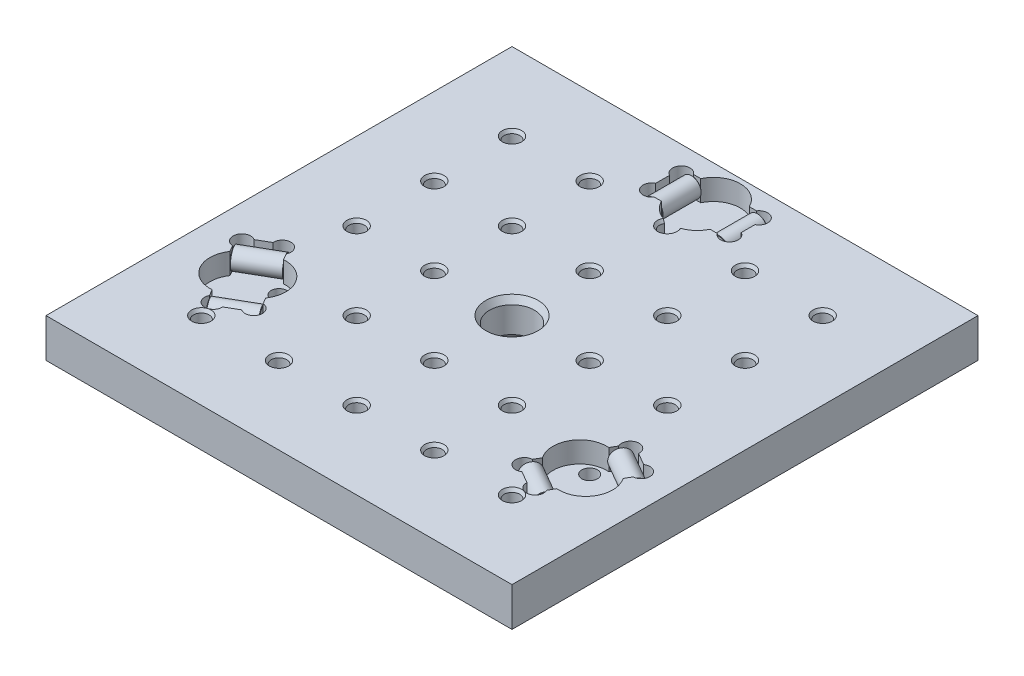
from build123d import *

# Parameters (mm, degrees)
SKETCH1_W            = 152.4
SKETCH1_H            = 152.4
EXTRUDE1_DEPTH       = 12.7
LPATTERN1_COUNT      = 5
LPATTERN1_PITCH      = 25.4
LPATTERN1_COUNT_DIR2 = 5
LPATTERN1_PITCH_DIR2 = 25.4
CUT_EXTRUDE1_DEPTH   = 6.858
CUT_EXTRUDE2_DEPTH   = 6.858
SKETCH10_R           = 3.175
EXTRUDE2_DEPTH       = 6.35
EXTRUDE2_2_DEPTH     = 6.35
CHAMFER1_SIZE        = 0.127
CHAMFER2_SIZE        = 0.127
CIRPATTERN4_COUNT    = 3
CIRPATTERN5_COUNT    = 3
SKETCH97_W           = 1.527820346
SKETCH97_H           = 0.474151141
CUT_EXTRUDE25_DEPTH  = 0.0762


with BuildPart() as part:
    # Sketch1 → Extrude1 (new body)
    with BuildSketch(Plane(origin=(0, 0, 0), x_dir=(1, 0, 0), z_dir=(0, 1, 0))):
        Rectangle(SKETCH1_W, SKETCH1_H)
    extrude(amount=EXTRUDE1_DEPTH)

    # Sketch4 → 5_8-18 Tapped Hole1 (revolve, cut)
    with BuildSketch(Plane(origin=(0, 12.7, 0), x_dir=(0, 0, 1), z_dir=(1, 0, 0))):
        Polygon((0, 0), (0, 12.7), (8.5725, 12.7), (7.34187, 10.568486315), (7.34187, 2.131513685), (8.5725, 0), align=None)
    revolve(axis=Axis((0, 19.05, 0), (0, -1, 0)), mode=Mode.SUBTRACT)

    # Sketch5 → 1_4-20 Tapped Hole1 (revolve, cut)
    with BuildSketch(Plane(origin=(-50.8, 12.7, -50.8), x_dir=(0, 0, 1), z_dir=(1, 0, 0))):
        Polygon((0, 0), (0, 12.7), (3.175, 12.7), (2.5527, 11.622144782), (2.5527, 1.077855218), (3.175, 0), align=None)
    f_1_4_20_tapped_hole1 = revolve(axis=Axis((-50.8, 19.05, -50.8), (0, -1, 0)), mode=Mode.SUBTRACT)

    # LPattern1: 1_4-20 Tapped Hole1 5 × 5, 1 skipped
    with Locations(*[(i * LPATTERN1_PITCH, 0, j * LPATTERN1_PITCH_DIR2) for i in range(LPATTERN1_COUNT) for j in range(LPATTERN1_COUNT_DIR2) if (i, j) not in ((0, 0), (2, 2))]):
        add(f_1_4_20_tapped_hole1, mode=Mode.SUBTRACT)

    # Sketch8 → Cut-Extrude1 (cut)
    with BuildSketch(Plane(origin=(0, 12.7, 0), x_dir=(-1, 0, 0), z_dir=(0, 1, 0))):
        with BuildLine():
            Line((7.9375, -69.6595), (7.9375, -56.8325))
            ThreePointArc((7.9375, -56.8325), (0, -51.816), (-7.9375, -56.8325))
            Line((-7.9375, -56.8325), (-7.9375, -69.6595))
            ThreePointArc((-7.9375, -69.6595), (0, -74.676), (7.9375, -69.6595))
        make_face()
    cut_extrude1 = extrude(amount=-CUT_EXTRUDE1_DEPTH, mode=Mode.SUBTRACT)

    # Sketch9 → Cut-Extrude2 (cut)
    with BuildSketch(Plane(origin=(0, 12.7, 0), x_dir=(-1, 0, 0), z_dir=(0, 1, 0))):
        with BuildLine():
            Line((-13.97, -65.512233165), (-13.97, -60.979766835))
            ThreePointArc((-13.97, -60.979766835), (-14.846098379, -56.533318257), (-10.324047559, -56.8325))
            Line((-10.324047559, -56.8325), (-7.9375, -56.8325))
            Line((-7.9375, -56.8325), (-7.9375, -69.6595))
            Line((-7.9375, -69.6595), (-10.324047559, -69.6595))
            ThreePointArc((-10.324047559, -69.6595), (-14.846098379, -69.958681743), (-13.97, -65.512233165))
        make_face()
        with BuildLine():
            Line((7.9375, -69.6595), (7.9375, -56.8325))
            Line((7.9375, -56.8325), (10.324047559, -56.8325))
            ThreePointArc((10.324047559, -56.8325), (14.846098379, -56.533318257), (13.97, -60.979766835))
            Line((13.97, -60.979766835), (13.97, -65.512233165))
            ThreePointArc((13.97, -65.512233165), (14.846098379, -69.958681743), (10.324047559, -69.6595))
            Line((10.324047559, -69.6595), (7.9375, -69.6595))
        make_face()
    cut_extrude2 = extrude(amount=-CUT_EXTRUDE2_DEPTH, mode=Mode.SUBTRACT)

    # CirPattern4: Cut-Extrude1, Cut-Extrude2 ×3 about axis
    cirpattern4_axis = Axis((0, 0, 0), (0, 1, 0))
    add([cut_extrude1.rotate(cirpattern4_axis, i * 360 / CIRPATTERN4_COUNT) for i in range(1, CIRPATTERN4_COUNT)], mode=Mode.SUBTRACT)
    add([cut_extrude2.rotate(cirpattern4_axis, i * 360 / CIRPATTERN4_COUNT) for i in range(1, CIRPATTERN4_COUNT)], mode=Mode.SUBTRACT)

    # Sketch97 → Cut-Extrude25 (cut)
    with BuildSketch(Plane(origin=(0, 0, -76.2), x_dir=(-1, 0, 0), z_dir=(0, 0, -1))):
        with BuildLine():
            Line((28.343701589, 8.89), (28.343701589, 4.780690104))
            Line((28.343701589, 4.780690104), (26.805179915, 4.780690104))
            add(Edge.make_bspline(
                [(26.805179915, 4.780690104), (26.767027271, 4.780837069), (26.692580616, 4.781123838), (26.583870621, 4.78825798), (26.480923337, 4.798056689), (26.383475532, 4.810548566), (26.292159048, 4.82915713), (26.206241303, 4.850130709), (26.126166613, 4.875632264), (26.028364377, 4.914665889), (25.915972121, 4.974246047), (25.795845315, 5.064344499), (25.691219749, 5.171552892), (25.60371681, 5.294067497), (25.534594896, 5.426352035), (25.483695852, 5.563436916), (25.451614062, 5.703641399), (25.447943468, 5.798523221), (25.446111278, 5.845883815)],
                knots=[0, 0, 0, 0, 0.939347082, 1.832933197, 2.68146557, 3.486110826, 4.250749273, 4.975125432, 5.663232023, 6.31822681, 7.566717696, 8.783012481, 10.001501375, 11.241036602, 12.477233666, 13.665923641, 14.834937602, 16, 16, 16, 16], degree=3))
            add(Edge.make_bspline(
                [(25.446111278, 5.845883815), (25.448029443, 5.889950382), (25.451847281, 5.977658674), (25.482209262, 6.106861747), (25.530059037, 6.231953365), (25.597517328, 6.352075791), (25.683483577, 6.465437327), (25.792018553, 6.566315567), (25.918574081, 6.657033193), (26.01364719, 6.705160765), (26.062672398, 6.729978132)],
                knots=[0, 0, 0, 0, 0.9266367, 1.844339749, 2.778522519, 3.737737271, 4.73460122, 5.760014721, 6.844933715, 8, 8, 8, 8], degree=3))
            add(Edge.make_bspline(
                [(26.062672398, 6.729978132), (26.032355949, 6.739468376), (25.9730015, 6.758048659), (25.887674658, 6.792049377), (25.807573685, 6.830758713), (25.73254819, 6.874264218), (25.663018861, 6.922882375), (25.599642241, 6.976876442), (25.54065759, 7.034364659), (25.488044634, 7.097172521), (25.441158142, 7.163934323), (25.399946612, 7.233763871), (25.365176883, 7.306463207), (25.337173228, 7.382040444), (25.314688945, 7.460390746), (25.299242268, 7.541954145), (25.290081105, 7.626484486), (25.288741754, 7.683745432), (25.288060897, 7.712853936)],
                knots=[0, 0, 0, 0, 1.127307071, 2.207075445, 3.256908754, 4.282608941, 5.282408985, 6.263870425, 7.234983269, 8.202720022, 9.167413107, 10.127917746, 11.077645759, 12.02382113, 12.985756818, 13.967604811, 14.966835385, 16, 16, 16, 16], degree=3))
            add(Edge.make_bspline(
                [(25.288060897, 7.712853936), (25.289371695, 7.759604508), (25.29197112, 7.852314976), (25.316112373, 7.988060339), (25.352938012, 8.119232659), (25.405671395, 8.242690266), (25.468517888, 8.357267108), (25.538968496, 8.459754921), (25.616848014, 8.548372818), (25.703374026, 8.62285082), (25.798997976, 8.686242285), (25.904927798, 8.740367396), (26.021826423, 8.786539687), (26.150489328, 8.8243588), (26.292528418, 8.853926746), (26.448798142, 8.874604377), (26.62000089, 8.888161147), (26.739022879, 8.889369918), (26.80106402, 8.89)],
                knots=[0, 0, 0, 0, 1.028264767, 2.039138877, 3.0256281, 4.021796415, 4.986880544, 5.898364145, 6.754107619, 7.576323729, 8.403891453, 9.273758037, 10.190131768, 11.166715241, 12.222223064, 13.380548297, 14.634590339, 16, 16, 16, 16], degree=3))
            Line((26.80106402, 8.89), (28.343701589, 8.89))
        make_face()
        with BuildLine():
            Line((27.764183527, 6.519244291), (26.917132268, 6.519244291))
            add(Edge.make_bspline(
                [(26.917132268, 6.519244291), (26.889414642, 6.519134629), (26.836162821, 6.518923945), (26.759348338, 6.515986377), (26.688452252, 6.513480211), (26.623748799, 6.507189927), (26.564917433, 6.501028874), (26.512193589, 6.492735135), (26.465319023, 6.483389974), (26.436617718, 6.474721633), (26.423224829, 6.470676726)],
                knots=[0, 0, 0, 0, 1.335841395, 2.566453063, 3.705076039, 4.753984432, 5.69893722, 6.555639608, 7.326018133, 8, 8, 8, 8], degree=3))
            add(Edge.make_bspline(
                [(26.423224829, 6.470676726), (26.391743301, 6.459668671), (26.331053502, 6.438447445), (26.249751718, 6.389868761), (26.17974209, 6.332527084), (26.122805167, 6.263581733), (26.078926377, 6.185119142), (26.047245007, 6.097331853), (26.02952658, 5.999976239), (26.026960242, 5.932114161), (26.02562934, 5.896920917)],
                knots=[0, 0, 0, 0, 1.058475706, 2.04051966, 2.99494362, 3.924783233, 4.866712143, 5.841396942, 6.880549411, 8, 8, 8, 8], degree=3))
            add(Edge.make_bspline(
                [(26.02562934, 5.896920917), (26.026690543, 5.863100034), (26.028758706, 5.797187032), (26.046245347, 5.701206754), (26.076327559, 5.612060138), (26.115884571, 5.529158253), (26.168200469, 5.456442373), (26.23029981, 5.394031401), (26.304164625, 5.346138892), (26.373217924, 5.316473689), (26.435289253, 5.297883421), (26.4907538, 5.286889521), (26.553665226, 5.277200941), (26.624232851, 5.268964612), (26.702482637, 5.262572292), (26.788655913, 5.257494072), (26.882547481, 5.255337972), (26.947589391, 5.255010944), (26.981340236, 5.254841246)],
                knots=[0, 0, 0, 0, 1.215868667, 2.369587816, 3.493110624, 4.592136066, 5.660239876, 6.700065329, 7.740218573, 8.805446038, 9.392473349, 10.067987094, 10.837083945, 11.681746432, 12.622633381, 13.660583752, 14.786055431, 16, 16, 16, 16], degree=3))
            Line((26.981340236, 5.254841246), (27.764183527, 5.254841246))
            Line((27.764183527, 5.254841246), (27.764183527, 6.519244291))
        make_face(mode=Mode.SUBTRACT)
        with BuildLine():
            Line((27.764183527, 8.415848858), (26.79200905, 8.415848858))
            add(Edge.make_bspline(
                [(26.79200905, 8.415848858), (26.753307879, 8.415939328), (26.682190247, 8.416105578), (26.585090185, 8.411277868), (26.506293222, 8.407115819), (26.460503995, 8.399442758), (26.440511589, 8.396092561)],
                knots=[0, 0, 0, 0, 1.317202051, 2.420502769, 3.310362904, 4, 4, 4, 4], degree=3))
            add(Edge.make_bspline(
                [(26.440511589, 8.396092561), (26.411823678, 8.390073866), (26.356276465, 8.378420118), (26.277794282, 8.352144933), (26.205590457, 8.322665787), (26.141435818, 8.284795967), (26.082831631, 8.240552057), (26.031372675, 8.186257609), (25.98360943, 8.124084452), (25.943333887, 8.052679979), (25.908994144, 7.974663184), (25.885533872, 7.889537561), (25.870215267, 7.799017784), (25.868469723, 7.736516819), (25.86757896, 7.704622145)],
                knots=[0, 0, 0, 0, 1.067695626, 2.067334776, 3.013065832, 3.905220739, 4.775573709, 5.681088305, 6.623427354, 7.627212225, 8.662261666, 9.723046264, 10.838054812, 12, 12, 12, 12], degree=3))
            add(Edge.make_bspline(
                [(25.86757896, 7.704622145), (25.868723212, 7.66721077), (25.87095462, 7.59425477), (25.891829316, 7.488735043), (25.927104106, 7.391115544), (25.974240216, 7.301043397), (26.035346073, 7.221759571), (26.10814844, 7.154864467), (26.191853, 7.100541273), (26.288666434, 7.058686655), (26.402096836, 7.02848369), (26.535117953, 7.008329419), (26.689669345, 6.995073478), (26.799934442, 6.993978739), (26.858686555, 6.993395433)],
                knots=[0, 0, 0, 0, 0.961406335, 1.874840495, 2.752092553, 3.623420628, 4.478799371, 5.312865821, 6.154540246, 7.033011991, 8.014031727, 9.164923062, 10.489397236, 12, 12, 12, 12], degree=3))
            Line((26.858686555, 6.993395433), (27.764183527, 6.993395433))
            Line((27.764183527, 6.993395433), (27.764183527, 8.415848858))
        make_face(mode=Mode.SUBTRACT)
        Polygon((25.112723756, 8.89), (23.481182848, 4.780690104), (22.82757867, 4.780690104), (21.196037762, 8.89), (21.810952524, 8.89), (22.278518233, 7.625596955), (24.030243285, 7.625596955), (24.497808994, 8.89), align=None)
        with BuildLine():
            Line((23.855729323, 7.151445813), (22.453032195, 7.151445813))
            Line((22.453032195, 7.151445813), (22.852274042, 6.071434879))
            add(Edge.make_bspline(
                [(22.852274042, 6.071434879), (22.867579549, 6.029704728), (22.897504705, 5.948114405), (22.942132129, 5.829570552), (22.982903023, 5.716996443), (23.022882234, 5.612006231), (23.058972181, 5.513074827), (23.092237211, 5.420870467), (23.125136044, 5.336034016), (23.144879097, 5.281220928), (23.154380759, 5.254841246)],
                knots=[0, 0, 0, 0, 1.225184869, 2.395467751, 3.491410812, 4.525364584, 5.492066482, 6.394148129, 7.227157926, 8, 8, 8, 8], degree=3))
            add(Edge.make_bspline(
                [(23.154380759, 5.254841246), (23.170136943, 5.319877723), (23.20177556, 5.450471796), (23.267181413, 5.641678626), (23.343229211, 5.830708302), (23.404311427, 5.952468973), (23.435084821, 6.013812345)],
                knots=[0, 0, 0, 0, 0.989154277, 1.986234384, 2.985459177, 4, 4, 4, 4], degree=3))
            Line((23.435084821, 6.013812345), (23.855729323, 7.151445813))
        make_face(mode=Mode.SUBTRACT)
        Polygon((20.75728332, 8.89), (20.75728332, 4.780690104), (20.177765258, 4.780690104), (20.177765258, 8.415848858), (18.22847723, 8.415848858), (18.22847723, 8.89), align=None)
        with Locations((17.148466296, 7.441204845)):
            Rectangle(SKETCH97_W, SKETCH97_H)
        Polygon((14.698685397, 8.89), (14.698685397, 5.254841246), (16.015771902, 5.254841246), (16.015771902, 4.780690104), (12.802080829, 4.780690104), (12.802080829, 5.254841246), (14.119167334, 5.254841246), (14.119167334, 8.89), align=None)
        Polygon((12.222562767, 8.89), (12.222562767, 4.780690104), (9.324972456, 4.780690104), (9.324972456, 5.254841246), (11.643044705, 5.254841246), (11.643044705, 6.519244291), (9.483022837, 6.519244291), (9.483022837, 6.993395433), (11.643044705, 6.993395433), (11.643044705, 8.415848858), (9.219605536, 8.415848858), (9.219605536, 8.89), align=None)
        with BuildLine():
            Line((5.637130242, 7.439558486), (5.057612179, 7.574559853))
            add(Edge.make_bspline(
                [(5.057612179, 7.574559853), (5.072130307, 7.628876821), (5.100529565, 7.735127552), (5.156685829, 7.887178222), (5.219686635, 8.029893584), (5.291184377, 8.16279463), (5.371403264, 8.285303502), (5.459992869, 8.39803532), (5.556940099, 8.501169334), (5.662988893, 8.593433147), (5.775378121, 8.6759567), (5.89489444, 8.746687593), (6.019417438, 8.808365112), (6.150983808, 8.857802991), (6.288627555, 8.895301307), (6.43200563, 8.922545218), (6.581466382, 8.939347167), (6.683346622, 8.941557415), (6.735251115, 8.94268346)],
                knots=[0, 0, 0, 0, 1.145367768, 2.240481511, 3.299486216, 4.322926322, 5.312543435, 6.280301985, 7.2416403, 8.192823262, 9.141388579, 10.079393599, 11.019812878, 11.970222822, 12.938950422, 13.923894909, 14.942295558, 16, 16, 16, 16], degree=3))
            add(Edge.make_bspline(
                [(6.735251115, 8.94268346), (6.788503627, 8.941899873), (6.892687911, 8.940366848), (7.045350109, 8.928193388), (7.19034707, 8.906355441), (7.328195566, 8.878421442), (7.457917988, 8.840071505), (7.580453197, 8.794322009), (7.69474375, 8.738930308), (7.801999137, 8.676088234), (7.901716387, 8.604657384), (7.996175479, 8.526610267), (8.083080009, 8.439786367), (8.164603798, 8.346238859), (8.238970993, 8.244732857), (8.308917644, 8.136647597), (8.371029678, 8.020078557), (8.427608923, 7.897186947), (8.477269736, 7.769162573), (8.521202185, 7.638534273), (8.557119364, 7.505041755), (8.588041737, 7.369808335), (8.610505343, 7.231696116), (8.628340751, 7.091741365), (8.638147016, 6.949086035), (8.639437417, 6.853194165), (8.640087473, 6.804887427)],
                knots=[0, 0, 0, 0, 1.180680974, 2.309907975, 3.39230657, 4.430402719, 5.425739985, 6.38846843, 7.327253855, 8.238163682, 9.141319901, 10.044148192, 10.951882972, 11.861898394, 12.79276478, 13.739539846, 14.714057202, 15.718574761, 16.737652364, 17.7573291, 18.772768038, 19.801551793, 20.831755737, 21.873891013, 22.928945814, 24, 24, 24, 24], degree=3))
            add(Edge.make_bspline(
                [(8.640087473, 6.804887427), (8.639157575, 6.752738413), (8.637320331, 6.649705134), (8.626953753, 6.497675536), (8.607899848, 6.350952204), (8.58148655, 6.209420917), (8.547835049, 6.072776527), (8.50686695, 5.940986776), (8.457993673, 5.814588284), (8.402488102, 5.693545144), (8.338643989, 5.57934203), (8.269937122, 5.470938673), (8.193545657, 5.370528083), (8.112272374, 5.275807022), (8.023024385, 5.189682203), (7.927858488, 5.110139411), (7.826624527, 5.03772562), (7.719490207, 4.972684763), (7.607789771, 4.915595068), (7.493377555, 4.86497965), (7.375810512, 4.822975321), (7.255381654, 4.788376353), (7.132249538, 4.761113884), (7.006256947, 4.742383268), (6.877615805, 4.730475643), (6.790704709, 4.728835601), (6.746775622, 4.728006644)],
                knots=[0, 0, 0, 0, 1.185683611, 2.342611346, 3.462256682, 4.54752026, 5.614193237, 6.659919581, 7.68288344, 8.693273043, 9.684551299, 10.655340776, 11.608553282, 12.550450986, 13.490114939, 14.424629326, 15.368095761, 16.317073336, 17.27126517, 18.21821065, 19.159447054, 20.107173046, 21.065292491, 22.024305098, 23.001387895, 24, 24, 24, 24], degree=3))
            add(Edge.make_bspline(
                [(6.746775622, 4.728006644), (6.697614783, 4.728889462), (6.600984286, 4.730624727), (6.459130203, 4.746247319), (6.322871649, 4.769118302), (6.193243291, 4.804526736), (6.068855487, 4.847570989), (5.951156316, 4.902613304), (5.83858633, 4.965678026), (5.733139151, 5.039477821), (5.634206324, 5.121480426), (5.543683248, 5.212719204), (5.45979411, 5.310718254), (5.385077513, 5.417977882), (5.316320716, 5.531881412), (5.257317094, 5.654868957), (5.204911792, 5.785124733), (5.177126852, 5.876110586), (5.1629791, 5.922439468)],
                knots=[0, 0, 0, 0, 1.098094218, 2.158412914, 3.185560839, 4.182001861, 5.157396189, 6.123029743, 7.081238243, 8.037090006, 8.994807998, 9.948592839, 10.905564776, 11.873472997, 12.866077505, 13.875170528, 14.918062841, 16, 16, 16, 16], degree=3))
            Line((5.1629791, 5.922439468), (5.742497162, 6.046739507))
            add(Edge.make_bspline(
                [(5.742497162, 6.046739507), (5.753876331, 6.011195101), (5.776148885, 5.9416237), (5.815724899, 5.842490464), (5.858359706, 5.750394652), (5.90546307, 5.66640255), (5.955564985, 5.589274308), (6.010006634, 5.519743005), (6.068629548, 5.457969499), (6.130537812, 5.402897412), (6.197255164, 5.356013412), (6.267358378, 5.3141759), (6.342509234, 5.280221305), (6.420985586, 5.25088412), (6.503698563, 5.228784122), (6.59042674, 5.213193281), (6.681279142, 5.204180438), (6.743188675, 5.20284095), (6.77476371, 5.202157786)],
                knots=[0, 0, 0, 0, 1.235448321, 2.418154634, 3.531842193, 4.593464837, 5.60397568, 6.574568355, 7.512901199, 8.420602914, 9.313080425, 10.209065825, 11.119673064, 12.039525284, 12.980625235, 13.950111628, 14.954518094, 16, 16, 16, 16], degree=3))
            add(Edge.make_bspline(
                [(6.77476371, 5.202157786), (6.811014759, 5.202684002), (6.882309873, 5.203718915), (6.987052805, 5.215037043), (7.087635466, 5.231725541), (7.183340425, 5.256686571), (7.274232792, 5.287909364), (7.360560139, 5.325943242), (7.442430547, 5.371372276), (7.519454218, 5.424211699), (7.591926858, 5.482198149), (7.657799212, 5.546295664), (7.719108374, 5.613997095), (7.77541021, 5.686201184), (7.824646459, 5.764399494), (7.869384981, 5.846696506), (7.907944879, 5.93405394), (7.951553134, 6.056564566), (7.994421264, 6.21466714), (8.032513815, 6.408016985), (8.056532224, 6.604249253), (8.059220837, 6.736222004), (8.060569411, 6.802417889)],
                knots=[0, 0, 0, 0, 0.93518376, 1.839230475, 2.715875874, 3.56435359, 4.38848637, 5.193784266, 5.995774969, 6.801072864, 7.601780706, 8.38807956, 9.17025402, 9.957795531, 10.747499049, 11.552298616, 12.373413868, 13.208937875, 14.906380835, 16.595160405, 18.29217494, 20, 20, 20, 20], degree=3))
            add(Edge.make_bspline(
                [(8.060569411, 6.802417889), (8.058902048, 6.885628853), (8.055662396, 7.047306), (8.028659999, 7.28162706), (7.982359979, 7.499526008), (7.929465607, 7.669701654), (7.875834459, 7.795300924), (7.832515467, 7.8832694), (7.783053966, 7.964668777), (7.728696676, 8.039964519), (7.668739164, 8.108936174), (7.604017854, 8.171950334), (7.534518, 8.229613288), (7.459416172, 8.279225745), (7.381603112, 8.323277279), (7.302060764, 8.362448745), (7.220739046, 8.395578237), (7.13730986, 8.421313899), (7.052944774, 8.443553089), (6.966714594, 8.458080772), (6.878643909, 8.466279738), (6.819506622, 8.467775438), (6.789580934, 8.468532318)],
                knots=[0, 0, 0, 0, 2.106789595, 4.093447702, 5.961877135, 7.741838795, 8.594923949, 9.418404614, 10.222784382, 11.003898572, 11.767382914, 12.533928212, 13.289274593, 14.050510641, 14.809809739, 15.552522078, 16.294453915, 17.030636788, 17.76204935, 18.502287276, 19.24210112, 20, 20, 20, 20], degree=3))
            add(Edge.make_bspline(
                [(6.789580934, 8.468532318), (6.753868682, 8.467783424), (6.683324357, 8.466304092), (6.579898123, 8.453353345), (6.480193971, 8.434273522), (6.385432315, 8.404813785), (6.294292639, 8.368804299), (6.207484749, 8.324068337), (6.124884417, 8.271071102), (6.046490794, 8.210342544), (5.97403549, 8.140790312), (5.90716138, 8.063878308), (5.845832728, 7.979595046), (5.791350392, 7.886922263), (5.744185605, 7.78587651), (5.700885226, 7.677896956), (5.664688815, 7.561706229), (5.646448394, 7.48085929), (5.637130242, 7.439558486)],
                knots=[0, 0, 0, 0, 1.013280452, 2.001587178, 2.954741544, 3.891007537, 4.813763809, 5.733392028, 6.65811846, 7.596035232, 8.543572245, 9.504144266, 10.485644879, 11.498176693, 12.550315313, 13.648080895, 14.798517897, 16, 16, 16, 16], degree=3))
        make_face()
        Polygon((-2.001971488, 8.89), (-2.001971488, 4.780690104), (-2.58148955, 4.780690104), (-2.58148955, 6.674001955), (-4.474801401, 4.780690104), (-5.26834602, 4.780690104), (-3.551194489, 6.497841635), (-5.373712941, 8.89), (-4.660016691, 8.89), (-3.184056626, 6.865802678), (-2.58148955, 7.467546575), (-2.58148955, 8.89), align=None)
        with BuildLine():
            Line((-5.795180622, 8.89), (-5.795180622, 4.780690104))
            Line((-5.795180622, 4.780690104), (-7.304891029, 4.780690104))
            add(Edge.make_bspline(
                [(-7.304891029, 4.780690104), (-7.36746786, 4.781036766), (-7.484713286, 4.781686279), (-7.648819594, 4.789630408), (-7.789756499, 4.799199107), (-7.875146157, 4.813063775), (-7.914043537, 4.81937952)],
                knots=[0, 0, 0, 0, 1.22865439, 2.302035814, 3.226529761, 4, 4, 4, 4], degree=3))
            add(Edge.make_bspline(
                [(-7.914043537, 4.81937952), (-7.961527063, 4.828399572), (-8.053647494, 4.845898926), (-8.183308285, 4.89008742), (-8.30259556, 4.942014627), (-8.409774173, 5.007662314), (-8.506008619, 5.086158807), (-8.59161383, 5.178874735), (-8.667069404, 5.28567021), (-8.732949325, 5.404637085), (-8.785076515, 5.534112627), (-8.823026748, 5.671031597), (-8.846977903, 5.814311278), (-8.849525947, 5.912191839), (-8.850821314, 5.961952063)],
                knots=[0, 0, 0, 0, 1.070866676, 2.077535254, 3.03113373, 3.95186103, 4.855919725, 5.777612234, 6.742027648, 7.750020258, 8.78762473, 9.830233769, 10.896940781, 12, 12, 12, 12], degree=3))
            add(Edge.make_bspline(
                [(-8.850821314, 5.961952063), (-8.849913901, 6.004529814), (-8.848128515, 6.08830387), (-8.832797833, 6.211380129), (-8.808617698, 6.329784187), (-8.772550949, 6.442707223), (-8.728454205, 6.551464143), (-8.672897722, 6.654240171), (-8.607966034, 6.752357851), (-8.533564958, 6.845982601), (-8.445096916, 6.931951656), (-8.33985981, 7.005510889), (-8.218879828, 7.067207065), (-8.082310619, 7.118510553), (-7.928995675, 7.155764933), (-7.760792588, 7.1850581), (-7.576290037, 7.200829531), (-7.448151087, 7.20299961), (-7.381446682, 7.204129274)],
                knots=[0, 0, 0, 0, 0.928803062, 1.827470905, 2.702365172, 3.562150579, 4.410580959, 5.259792768, 6.106763965, 6.975510033, 7.86481326, 8.788506802, 9.766003746, 10.821436188, 11.964367758, 13.203725265, 14.544362639, 16, 16, 16, 16], degree=3))
            Line((-7.381446682, 7.204129274), (-6.374698685, 7.204129274))
            Line((-6.374698685, 7.204129274), (-6.374698685, 8.89))
            Line((-6.374698685, 8.89), (-5.795180622, 8.89))
        make_face()
        with BuildLine():
            Line((-6.374698685, 6.729978132), (-7.36580628, 6.729978132))
            add(Edge.make_bspline(
                [(-7.36580628, 6.729978132), (-7.405334704, 6.729314654), (-7.48148255, 6.728036526), (-7.591526273, 6.719184893), (-7.692470835, 6.703689808), (-7.784894377, 6.682599805), (-7.868111402, 6.654625265), (-7.943053239, 6.621181117), (-8.00859892, 6.580654249), (-8.065426422, 6.533906489), (-8.114188567, 6.48150672), (-8.156481794, 6.424366006), (-8.192138959, 6.362203248), (-8.220708134, 6.294897441), (-8.244319349, 6.223192758), (-8.259245863, 6.145727534), (-8.269581537, 6.063756816), (-8.2707213, 6.007261561), (-8.271303252, 5.978415645)],
                knots=[0, 0, 0, 0, 1.40421292, 2.705086056, 3.918275699, 5.029558377, 6.068365212, 7.032404237, 7.938575147, 8.797260087, 9.638618655, 10.474993364, 11.317706051, 12.177828306, 13.068718597, 13.993981992, 14.975747128, 16, 16, 16, 16], degree=3))
            add(Edge.make_bspline(
                [(-8.271303252, 5.978415645), (-8.270074069, 5.936585355), (-8.267692342, 5.855532859), (-8.243749166, 5.738877103), (-8.206098335, 5.631173817), (-8.152694433, 5.53423877), (-8.086648019, 5.450153286), (-8.011331748, 5.379485778), (-7.924766748, 5.325304342), (-7.86131685, 5.302555795), (-7.829256094, 5.291061125)],
                knots=[0, 0, 0, 0, 1.143451971, 2.215610693, 3.244091205, 4.255765529, 5.229231363, 6.159234871, 7.069875225, 8, 8, 8, 8], degree=3))
            add(Edge.make_bspline(
                [(-7.829256094, 5.291061125), (-7.817485464, 5.288182946), (-7.791907078, 5.281928465), (-7.749536681, 5.274829535), (-7.700431623, 5.268107479), (-7.644352541, 5.263647708), (-7.581810864, 5.259218588), (-7.512615393, 5.257176874), (-7.436608502, 5.255413415), (-7.383643233, 5.255037796), (-7.355928131, 5.254841246)],
                knots=[0, 0, 0, 0, 0.611063981, 1.327884044, 2.165719042, 3.110592661, 4.16481496, 5.328235826, 6.601947678, 8, 8, 8, 8], degree=3))
            Line((-7.355928131, 5.254841246), (-6.374698685, 5.254841246))
            Line((-6.374698685, 5.254841246), (-6.374698685, 6.729978132))
        make_face(mode=Mode.SUBTRACT)
        with Locations((-10.036199169, 7.441204845)):
            Rectangle(SKETCH97_W, SKETCH97_H)
        with BuildLine():
            Line((-13.855750033, 5.834359308), (-13.328915431, 5.887042768))
            add(Edge.make_bspline(
                [(-13.328915431, 5.887042768), (-13.317546765, 5.841732182), (-13.296146999, 5.756441976), (-13.25127189, 5.640758679), (-13.201820478, 5.542910286), (-13.158857949, 5.490221628), (-13.138761067, 5.465575087)],
                knots=[0, 0, 0, 0, 1.199207122, 2.257322842, 3.184815751, 4, 4, 4, 4], degree=3))
            add(Edge.make_bspline(
                [(-13.138761067, 5.465575087), (-13.121510231, 5.448764793), (-13.087581831, 5.415702835), (-13.031883746, 5.372606337), (-12.973168745, 5.336092822), (-12.911259368, 5.306511339), (-12.846490077, 5.283143666), (-12.778592584, 5.266796734), (-12.707720705, 5.256677056), (-12.659430371, 5.255458393), (-12.634975479, 5.254841246)],
                knots=[0, 0, 0, 0, 1.028360939, 2.022547923, 3.001693811, 3.976902288, 4.948369586, 5.937776631, 6.955661634, 8, 8, 8, 8], degree=3))
            add(Edge.make_bspline(
                [(-12.634975479, 5.254841246), (-12.595329892, 5.256117785), (-12.516991944, 5.258640169), (-12.402056173, 5.283334125), (-12.290421231, 5.320292568), (-12.221259258, 5.35775757), (-12.186342888, 5.376671748)],
                knots=[0, 0, 0, 0, 1.010336883, 1.996381556, 2.988474728, 4, 4, 4, 4], degree=3))
            add(Edge.make_bspline(
                [(-12.186342888, 5.376671748), (-12.152012459, 5.405126299), (-12.081540301, 5.463536685), (-11.989675866, 5.571084386), (-11.908077543, 5.696673799), (-11.846977467, 5.813657652), (-11.805122539, 5.919498963), (-11.775968388, 6.009484979), (-11.752789557, 6.109283542), (-11.733004698, 6.218075501), (-11.71784205, 6.336268475), (-11.705124911, 6.463865954), (-11.698101108, 6.601212851), (-11.696535474, 6.695946579), (-11.695728165, 6.744795355)],
                knots=[0, 0, 0, 0, 1.063396562, 2.182898711, 3.360648584, 4.635554171, 5.326740425, 6.076945788, 6.892323083, 7.771510239, 8.716835194, 9.737306867, 10.833258317, 12, 12, 12, 12], degree=3))
            add(Edge.make_bspline(
                [(-11.695728165, 6.744795355), (-11.726798743, 6.701168872), (-11.787621295, 6.615767369), (-11.894887413, 6.50369367), (-12.012728529, 6.409769198), (-12.139905078, 6.334148566), (-12.27332612, 6.275518689), (-12.410896472, 6.234807911), (-12.551303637, 6.207463615), (-12.646371543, 6.204590386), (-12.694244372, 6.20314353)],
                knots=[0, 0, 0, 0, 1.08413448, 2.122259381, 3.131196715, 4.128532876, 5.111902129, 6.075762527, 7.031022177, 8, 8, 8, 8], degree=3))
            add(Edge.make_bspline(
                [(-12.694244372, 6.20314353), (-12.735457934, 6.204249001), (-12.816883164, 6.206433071), (-12.93676786, 6.223841733), (-13.05154231, 6.2539613), (-13.162274613, 6.294141699), (-13.267501187, 6.347463835), (-13.369002071, 6.410896753), (-13.464545795, 6.487649572), (-13.555320263, 6.574009076), (-13.638389732, 6.669985497), (-13.710754674, 6.77380424), (-13.772544281, 6.884164083), (-13.82167149, 7.00174449), (-13.86060127, 7.126013781), (-13.888389084, 7.256899834), (-13.905115875, 7.39467374), (-13.907310654, 7.488627342), (-13.908433494, 7.536693616)],
                knots=[0, 0, 0, 0, 0.98160025, 1.939337942, 2.877944864, 3.804478064, 4.739961265, 5.683019169, 6.650831814, 7.654132266, 8.664499124, 9.669140276, 10.664058004, 11.671756914, 12.699296594, 13.762159139, 14.855129872, 16, 16, 16, 16], degree=3))
            add(Edge.make_bspline(
                [(-13.908433494, 7.536693616), (-13.906344794, 7.600201696), (-13.902213898, 7.725803941), (-13.870249982, 7.91056527), (-13.816912161, 8.087981371), (-13.756415673, 8.2296243), (-13.697165457, 8.336473958), (-13.649591309, 8.412716921), (-13.597238024, 8.48366227), (-13.541819788, 8.550589831), (-13.480919145, 8.611282903), (-13.418029608, 8.66873557), (-13.349658413, 8.719597073), (-13.278576762, 8.766760832), (-13.203331394, 8.807561054), (-13.126021975, 8.84409086), (-13.045931202, 8.874622278), (-12.963273532, 8.899107766), (-12.878419744, 8.919153806), (-12.790926799, 8.932973379), (-12.701001693, 8.941487144), (-12.640208111, 8.942281601), (-12.609456928, 8.94268346)],
                knots=[0, 0, 0, 0, 1.777706882, 3.515835744, 5.23207167, 6.95628682, 7.816020017, 8.65165611, 9.4707737, 10.283378767, 11.082060806, 11.8764812, 12.666355411, 13.46551777, 14.263312302, 15.060773764, 15.858457287, 16.660642738, 17.473247806, 18.298111139, 19.139134514, 20, 20, 20, 20], degree=3))
            add(Edge.make_bspline(
                [(-12.609456928, 8.94268346), (-12.557525269, 8.941239727), (-12.455678153, 8.938408314), (-12.306585161, 8.916761221), (-12.164860392, 8.880251557), (-12.030256985, 8.830187146), (-11.903065791, 8.765486579), (-11.783727947, 8.6855705), (-11.67172987, 8.591427822), (-11.566913296, 8.483010552), (-11.472225815, 8.357452094), (-11.389679863, 8.213583377), (-11.322066187, 8.05021008), (-11.264958227, 7.869371029), (-11.222676733, 7.669355437), (-11.190068494, 7.451455275), (-11.172917474, 7.214830729), (-11.170266342, 7.05104183), (-11.168893563, 6.966230524)],
                knots=[0, 0, 0, 0, 0.898449204, 1.762016875, 2.600428026, 3.426826527, 4.242280324, 5.064055083, 5.906691075, 6.769749479, 7.668135943, 8.621070442, 9.631748766, 10.722023185, 11.898351526, 13.165512303, 14.532277789, 16, 16, 16, 16], degree=3))
            add(Edge.make_bspline(
                [(-11.168893563, 6.966230524), (-11.169224728, 6.917934438), (-11.169877828, 6.822688469), (-11.174581711, 6.682391224), (-11.183856677, 6.547088742), (-11.196047843, 6.416957454), (-11.211755565, 6.291789044), (-11.230193881, 6.171664632), (-11.253718466, 6.056752343), (-11.279602324, 5.946798326), (-11.30962955, 5.841727083), (-11.341897483, 5.741406079), (-11.379347439, 5.646570334), (-11.419542217, 5.556645288), (-11.463280954, 5.471762688), (-11.509845247, 5.391596264), (-11.56131812, 5.317174363), (-11.598336564, 5.27055999), (-11.616702975, 5.247432634)],
                knots=[0, 0, 0, 0, 1.280444348, 2.525197649, 3.720942618, 4.875526429, 5.989898656, 7.065115415, 8.096622082, 9.098853712, 10.059152529, 10.993162051, 11.891531392, 12.760921141, 13.603603485, 14.422073071, 15.217123906, 16, 16, 16, 16], degree=3))
            add(Edge.make_bspline(
                [(-11.616702975, 5.247432634), (-11.649889074, 5.21010481), (-11.715301956, 5.136528203), (-11.82720283, 5.041484655), (-11.946442639, 4.960302843), (-12.074923112, 4.894714967), (-12.211662266, 4.843580553), (-12.356745823, 4.8064615), (-12.510578636, 4.784935011), (-12.615699991, 4.782128008), (-12.669549, 4.780690104)],
                knots=[0, 0, 0, 0, 1.005002357, 1.980952959, 2.948226316, 3.90482984, 4.879026092, 5.883055346, 6.915583142, 8, 8, 8, 8], degree=3))
            add(Edge.make_bspline(
                [(-12.669549, 4.780690104), (-12.709645565, 4.781398888), (-12.788418497, 4.78279135), (-12.903840949, 4.796152165), (-13.013627983, 4.818482763), (-13.118024123, 4.848604244), (-13.216422335, 4.888699781), (-13.309957031, 4.936217333), (-13.397678442, 4.993377962), (-13.478951509, 5.059400726), (-13.553977545, 5.13241406), (-13.621177322, 5.213031094), (-13.680297635, 5.300247062), (-13.731800812, 5.394243354), (-13.775226628, 5.494575022), (-13.81088138, 5.601673281), (-13.837981371, 5.715510608), (-13.849745046, 5.794193939), (-13.855750033, 5.834359308)],
                knots=[0, 0, 0, 0, 1.095988384, 2.15315746, 3.171326302, 4.156539379, 5.119213808, 6.072133135, 7.021027441, 7.975952916, 8.930907862, 9.879001051, 10.840359051, 11.807350428, 12.805278655, 13.825435679, 14.889953203, 16, 16, 16, 16], degree=3))
        make_face()
        with BuildLine():
            add(Edge.make_bspline(
                [(-11.695728165, 7.525992288), (-11.697201556, 7.567240654), (-11.700128994, 7.649195873), (-11.722232581, 7.770630502), (-11.758935633, 7.888943524), (-11.80852298, 8.003191557), (-11.870396674, 8.109539766), (-11.942983808, 8.204382866), (-12.026085198, 8.285233341), (-12.119150459, 8.35170407), (-12.220944273, 8.403346431), (-12.330012583, 8.442094439), (-12.447203486, 8.464449498), (-12.527868097, 8.467150822), (-12.569121154, 8.468532318)],
                knots=[0, 0, 0, 0, 1.034371533, 2.055163721, 3.085036369, 4.136219926, 5.172765015, 6.164074703, 7.123048089, 8.070464312, 9.021723619, 9.977430468, 10.965628467, 12, 12, 12, 12], degree=3))
            add(Edge.make_bspline(
                [(-12.569121154, 8.468532318), (-12.598525549, 8.467740695), (-12.655920327, 8.466195517), (-12.739932197, 8.454117673), (-12.819926268, 8.435863313), (-12.895527016, 8.407924756), (-12.967260983, 8.373724752), (-13.034771016, 8.330977009), (-13.098075476, 8.280879856), (-13.15649139, 8.223117892), (-13.209293686, 8.158893944), (-13.255170042, 8.088581398), (-13.295683656, 8.013342716), (-13.326156239, 7.931327391), (-13.350987018, 7.844636995), (-13.369242373, 7.752451726), (-13.379960189, 7.654665773), (-13.381044747, 7.587483409), (-13.381598892, 7.553157197)],
                knots=[0, 0, 0, 0, 1.023462019, 1.997707343, 2.950204755, 3.875082018, 4.798131411, 5.712685617, 6.65128003, 7.603921197, 8.567945975, 9.540503156, 10.523517238, 11.53671457, 12.580096959, 13.661292135, 14.805058716, 16, 16, 16, 16], degree=3))
            add(Edge.make_bspline(
                [(-13.381598892, 7.553157197), (-13.381085543, 7.520194028), (-13.380081627, 7.455730391), (-13.368763411, 7.361667743), (-13.352318427, 7.27273213), (-13.326845835, 7.189487491), (-13.296199132, 7.111449885), (-13.257816452, 7.03884705), (-13.212284407, 6.971746528), (-13.159701723, 6.910331322), (-13.101540319, 6.85495236), (-13.037121275, 6.807600419), (-12.968098953, 6.767392672), (-12.893988961, 6.733971599), (-12.814688427, 6.708554188), (-12.730241857, 6.690907705), (-12.641097375, 6.678598626), (-12.579866503, 6.677735986), (-12.548541677, 6.677294671)],
                knots=[0, 0, 0, 0, 1.155242457, 2.259222408, 3.317825484, 4.322358011, 5.306829979, 6.253722241, 7.195762508, 8.144412979, 9.083697585, 10.00547228, 10.941152501, 11.87999348, 12.850638972, 13.854618393, 14.902453872, 16, 16, 16, 16], degree=3))
            add(Edge.make_bspline(
                [(-12.548541677, 6.677294671), (-12.519409187, 6.677749418), (-12.462000848, 6.678645538), (-12.377815681, 6.691059313), (-12.296660346, 6.708709728), (-12.218943039, 6.734502538), (-12.144544471, 6.76721526), (-12.074334804, 6.808502142), (-12.006139578, 6.854886669), (-11.943547937, 6.910456601), (-11.884886183, 6.97041303), (-11.834709394, 7.036893805), (-11.791634283, 7.107166902), (-11.755767816, 7.181725446), (-11.728520294, 7.261314863), (-11.710025524, 7.345584496), (-11.698096717, 7.434281216), (-11.696529966, 7.494946306), (-11.695728165, 7.525992288)],
                knots=[0, 0, 0, 0, 1.03701548, 2.04353757, 3.025450354, 3.993097303, 4.955942005, 5.915106969, 6.891406964, 7.889250744, 8.89182446, 9.875341956, 10.849485896, 11.824610452, 12.817027865, 13.839237692, 14.894207727, 16, 16, 16, 16], degree=3))
        make_face(mode=Mode.SUBTRACT)
        with Locations((-15.093811348, 7.441204845)):
            Rectangle(SKETCH97_W, SKETCH97_H)
        with BuildLine():
            Line((-18.913362213, 5.834359308), (-18.386527611, 5.887042768))
            add(Edge.make_bspline(
                [(-18.386527611, 5.887042768), (-18.375158944, 5.841732182), (-18.353759178, 5.756441976), (-18.30888407, 5.640758679), (-18.259432658, 5.542910286), (-18.216470129, 5.490221628), (-18.196373247, 5.465575087)],
                knots=[0, 0, 0, 0, 1.199207122, 2.257322842, 3.184815751, 4, 4, 4, 4], degree=3))
            add(Edge.make_bspline(
                [(-18.196373247, 5.465575087), (-18.179122411, 5.448764793), (-18.14519401, 5.415702835), (-18.089495925, 5.372606337), (-18.030780924, 5.336092822), (-17.968871548, 5.306511339), (-17.904102256, 5.283143666), (-17.836204763, 5.266796734), (-17.765332884, 5.256677056), (-17.71704255, 5.255458393), (-17.692587658, 5.254841246)],
                knots=[0, 0, 0, 0, 1.028360939, 2.022547923, 3.001693811, 3.976902288, 4.948369586, 5.937776631, 6.955661634, 8, 8, 8, 8], degree=3))
            add(Edge.make_bspline(
                [(-17.692587658, 5.254841246), (-17.652942072, 5.256117785), (-17.574604123, 5.258640169), (-17.459668353, 5.283334125), (-17.348033411, 5.320292568), (-17.278871438, 5.35775757), (-17.243955068, 5.376671748)],
                knots=[0, 0, 0, 0, 1.010336883, 1.996381556, 2.988474728, 4, 4, 4, 4], degree=3))
            add(Edge.make_bspline(
                [(-17.243955068, 5.376671748), (-17.209624638, 5.405126299), (-17.13915248, 5.463536685), (-17.047288046, 5.571084386), (-16.965689723, 5.696673799), (-16.904589647, 5.813657652), (-16.862734719, 5.919498963), (-16.833580568, 6.009484979), (-16.810401736, 6.109283542), (-16.790616877, 6.218075501), (-16.775454229, 6.336268475), (-16.762737091, 6.463865954), (-16.755713288, 6.601212851), (-16.754147653, 6.695946579), (-16.753340345, 6.744795355)],
                knots=[0, 0, 0, 0, 1.063396562, 2.182898711, 3.360648584, 4.635554171, 5.326740425, 6.076945788, 6.892323083, 7.771510239, 8.716835194, 9.737306867, 10.833258317, 12, 12, 12, 12], degree=3))
            add(Edge.make_bspline(
                [(-16.753340345, 6.744795355), (-16.784410922, 6.701168872), (-16.845233474, 6.615767369), (-16.952499593, 6.50369367), (-17.070340709, 6.409769198), (-17.197517257, 6.334148566), (-17.330938299, 6.275518689), (-17.468508652, 6.234807911), (-17.608915817, 6.207463615), (-17.703983722, 6.204590386), (-17.751856551, 6.20314353)],
                knots=[0, 0, 0, 0, 1.08413448, 2.122259381, 3.131196715, 4.128532876, 5.111902129, 6.075762527, 7.031022177, 8, 8, 8, 8], degree=3))
            add(Edge.make_bspline(
                [(-17.751856551, 6.20314353), (-17.793070114, 6.204249001), (-17.874495343, 6.206433071), (-17.994380039, 6.223841733), (-18.10915449, 6.2539613), (-18.219886793, 6.294141699), (-18.325113367, 6.347463835), (-18.42661425, 6.410896753), (-18.522157974, 6.487649572), (-18.612932442, 6.574009076), (-18.696001911, 6.669985497), (-18.768366854, 6.77380424), (-18.830156461, 6.884164083), (-18.87928367, 7.00174449), (-18.91821345, 7.126013781), (-18.946001264, 7.256899834), (-18.962728054, 7.39467374), (-18.964922833, 7.488627342), (-18.966045673, 7.536693616)],
                knots=[0, 0, 0, 0, 0.98160025, 1.939337942, 2.877944864, 3.804478064, 4.739961265, 5.683019169, 6.650831814, 7.654132266, 8.664499124, 9.669140276, 10.664058004, 11.671756914, 12.699296594, 13.762159139, 14.855129872, 16, 16, 16, 16], degree=3))
            add(Edge.make_bspline(
                [(-18.966045673, 7.536693616), (-18.963956974, 7.600201696), (-18.959826077, 7.725803941), (-18.927862161, 7.91056527), (-18.874524341, 8.087981371), (-18.814027853, 8.2296243), (-18.754777636, 8.336473958), (-18.707203488, 8.412716921), (-18.654850203, 8.48366227), (-18.599431968, 8.550589831), (-18.538531324, 8.611282903), (-18.475641787, 8.66873557), (-18.407270593, 8.719597073), (-18.336188941, 8.766760832), (-18.260943573, 8.807561054), (-18.183634155, 8.84409086), (-18.103543382, 8.874622278), (-18.020885712, 8.899107766), (-17.936031923, 8.919153806), (-17.848538978, 8.932973379), (-17.758613872, 8.941487144), (-17.697820291, 8.942281601), (-17.667069107, 8.94268346)],
                knots=[0, 0, 0, 0, 1.777706882, 3.515835744, 5.23207167, 6.95628682, 7.816020017, 8.65165611, 9.4707737, 10.283378767, 11.082060806, 11.8764812, 12.666355411, 13.46551777, 14.263312302, 15.060773764, 15.858457287, 16.660642738, 17.473247806, 18.298111139, 19.139134514, 20, 20, 20, 20], degree=3))
            add(Edge.make_bspline(
                [(-17.667069107, 8.94268346), (-17.615137448, 8.941239727), (-17.513290333, 8.938408314), (-17.364197341, 8.916761221), (-17.222472571, 8.880251557), (-17.087869165, 8.830187146), (-16.96067797, 8.765486579), (-16.841340127, 8.6855705), (-16.729342049, 8.591427822), (-16.624525476, 8.483010552), (-16.529837994, 8.357452094), (-16.447292042, 8.213583377), (-16.379678367, 8.05021008), (-16.322570407, 7.869371029), (-16.280288913, 7.669355437), (-16.247680673, 7.451455275), (-16.230529653, 7.214830729), (-16.227878521, 7.05104183), (-16.226505743, 6.966230524)],
                knots=[0, 0, 0, 0, 0.898449204, 1.762016875, 2.600428026, 3.426826527, 4.242280324, 5.064055083, 5.906691075, 6.769749479, 7.668135943, 8.621070442, 9.631748766, 10.722023185, 11.898351526, 13.165512303, 14.532277789, 16, 16, 16, 16], degree=3))
            add(Edge.make_bspline(
                [(-16.226505743, 6.966230524), (-16.226836908, 6.917934438), (-16.227490007, 6.822688469), (-16.232193891, 6.682391224), (-16.241468856, 6.547088742), (-16.253660023, 6.416957454), (-16.269367745, 6.291789044), (-16.28780606, 6.171664632), (-16.311330645, 6.056752343), (-16.337214504, 5.946798326), (-16.36724173, 5.841727083), (-16.399509662, 5.741406079), (-16.436959619, 5.646570334), (-16.477154396, 5.556645288), (-16.520893134, 5.471762688), (-16.567457426, 5.391596264), (-16.618930299, 5.317174363), (-16.655948743, 5.27055999), (-16.674315154, 5.247432634)],
                knots=[0, 0, 0, 0, 1.280444348, 2.525197649, 3.720942618, 4.875526429, 5.989898656, 7.065115415, 8.096622082, 9.098853712, 10.059152529, 10.993162051, 11.891531392, 12.760921141, 13.603603485, 14.422073071, 15.217123906, 16, 16, 16, 16], degree=3))
            add(Edge.make_bspline(
                [(-16.674315154, 5.247432634), (-16.707501253, 5.21010481), (-16.772914135, 5.136528203), (-16.88481501, 5.041484655), (-17.004054818, 4.960302843), (-17.132535292, 4.894714967), (-17.269274445, 4.843580553), (-17.414358002, 4.8064615), (-17.568190815, 4.784935011), (-17.673312171, 4.782128008), (-17.727161179, 4.780690104)],
                knots=[0, 0, 0, 0, 1.005002357, 1.980952959, 2.948226316, 3.90482984, 4.879026092, 5.883055346, 6.915583142, 8, 8, 8, 8], degree=3))
            add(Edge.make_bspline(
                [(-17.727161179, 4.780690104), (-17.767257745, 4.781398888), (-17.846030677, 4.78279135), (-17.961453128, 4.796152165), (-18.071240162, 4.818482763), (-18.175636303, 4.848604244), (-18.274034515, 4.888699781), (-18.367569211, 4.936217333), (-18.455290621, 4.993377962), (-18.536563689, 5.059400726), (-18.611589725, 5.13241406), (-18.678789501, 5.213031094), (-18.737909815, 5.300247062), (-18.789412992, 5.394243354), (-18.832838807, 5.494575022), (-18.86849356, 5.601673281), (-18.89559355, 5.715510608), (-18.907357226, 5.794193939), (-18.913362213, 5.834359308)],
                knots=[0, 0, 0, 0, 1.095988384, 2.15315746, 3.171326302, 4.156539379, 5.119213808, 6.072133135, 7.021027441, 7.975952916, 8.930907862, 9.879001051, 10.840359051, 11.807350428, 12.805278655, 13.825435679, 14.889953203, 16, 16, 16, 16], degree=3))
        make_face()
        with BuildLine():
            add(Edge.make_bspline(
                [(-16.753340345, 7.525992288), (-16.754813735, 7.567240654), (-16.757741173, 7.649195873), (-16.779844761, 7.770630502), (-16.816547812, 7.888943524), (-16.866135159, 8.003191557), (-16.928008854, 8.109539766), (-17.000595987, 8.204382866), (-17.083697377, 8.285233341), (-17.176762639, 8.35170407), (-17.278556453, 8.403346431), (-17.387624762, 8.442094439), (-17.504815666, 8.464449498), (-17.585480276, 8.467150822), (-17.626733333, 8.468532318)],
                knots=[0, 0, 0, 0, 1.034371533, 2.055163721, 3.085036369, 4.136219926, 5.172765015, 6.164074703, 7.123048089, 8.070464312, 9.021723619, 9.977430468, 10.965628467, 12, 12, 12, 12], degree=3))
            add(Edge.make_bspline(
                [(-17.626733333, 8.468532318), (-17.656137728, 8.467740695), (-17.713532506, 8.466195517), (-17.797544377, 8.454117673), (-17.877538447, 8.435863313), (-17.953139195, 8.407924756), (-18.024873162, 8.373724752), (-18.092383195, 8.330977009), (-18.155687655, 8.280879856), (-18.21410357, 8.223117892), (-18.266905865, 8.158893944), (-18.312782221, 8.088581398), (-18.353295836, 8.013342716), (-18.383768418, 7.931327391), (-18.408599197, 7.844636995), (-18.426854552, 7.752451726), (-18.437572369, 7.654665773), (-18.438656926, 7.587483409), (-18.439211071, 7.553157197)],
                knots=[0, 0, 0, 0, 1.023462019, 1.997707343, 2.950204755, 3.875082018, 4.798131411, 5.712685617, 6.65128003, 7.603921197, 8.567945975, 9.540503156, 10.523517238, 11.53671457, 12.580096959, 13.661292135, 14.805058716, 16, 16, 16, 16], degree=3))
            add(Edge.make_bspline(
                [(-18.439211071, 7.553157197), (-18.438697723, 7.520194028), (-18.437693806, 7.455730391), (-18.426375591, 7.361667743), (-18.409930607, 7.27273213), (-18.384458014, 7.189487491), (-18.353811312, 7.111449885), (-18.315428632, 7.03884705), (-18.269896587, 6.971746528), (-18.217313902, 6.910331322), (-18.159152498, 6.85495236), (-18.094733455, 6.807600419), (-18.025711132, 6.767392672), (-17.95160114, 6.733971599), (-17.872300606, 6.708554188), (-17.787854037, 6.690907705), (-17.698709555, 6.678598626), (-17.637478683, 6.677735986), (-17.606153857, 6.677294671)],
                knots=[0, 0, 0, 0, 1.155242457, 2.259222408, 3.317825484, 4.322358011, 5.306829979, 6.253722241, 7.195762508, 8.144412979, 9.083697585, 10.00547228, 10.941152501, 11.87999348, 12.850638972, 13.854618393, 14.902453872, 16, 16, 16, 16], degree=3))
            add(Edge.make_bspline(
                [(-17.606153857, 6.677294671), (-17.577021367, 6.677749418), (-17.519613027, 6.678645538), (-17.435427861, 6.691059313), (-17.354272526, 6.708709728), (-17.276555218, 6.734502538), (-17.202156651, 6.76721526), (-17.131946984, 6.808502142), (-17.063751758, 6.854886669), (-17.001160117, 6.910456601), (-16.942498362, 6.97041303), (-16.892321574, 7.036893805), (-16.849246462, 7.107166902), (-16.813379996, 7.181725446), (-16.786132473, 7.261314863), (-16.767637704, 7.345584496), (-16.755708897, 7.434281216), (-16.754142145, 7.494946306), (-16.753340345, 7.525992288)],
                knots=[0, 0, 0, 0, 1.03701548, 2.04353757, 3.025450354, 3.993097303, 4.955942005, 5.915106969, 6.891406964, 7.889250744, 8.89182446, 9.875341956, 10.849485896, 11.824610452, 12.817027865, 13.839237692, 14.894207727, 16, 16, 16, 16], degree=3))
        make_face(mode=Mode.SUBTRACT)
        with Locations((-20.151423528, 7.441204845)):
            Rectangle(SKETCH97_W, SKETCH97_H)
        Polygon((-21.600218683, 8.89), (-21.600218683, 4.780690104), (-22.179736745, 4.780690104), (-22.179736745, 6.466560831), (-24.181708233, 6.466560831), (-24.181708233, 4.780690104), (-24.761226295, 4.780690104), (-24.761226295, 8.89), (-24.181708233, 8.89), (-24.181708233, 6.940711972), (-22.179736745, 6.940711972), (-22.179736745, 8.89), align=None)
        Polygon((-26.710514323, 8.89), (-26.710514323, 5.254841246), (-25.393427818, 5.254841246), (-25.393427818, 4.780690104), (-28.60711889, 4.780690104), (-28.60711889, 5.254841246), (-27.290032385, 5.254841246), (-27.290032385, 8.89), align=None)
    extrude(amount=-CUT_EXTRUDE25_DEPTH, mode=Mode.SUBTRACT)


with BuildPart() as body_2:
    # Sketch10 → Extrude2 (new body, symmetric)
    with BuildSketch(Plane.XY.offset(-63.246)):
        with Locations((10.795, 9.017)):
            Circle(SKETCH10_R)
    extrude(amount=EXTRUDE2_DEPTH, both=True)

    # Chamfer2
    chamfer2_edges = [body_2.edges().sort_by_distance(p)[0] for p in [
        (7.62, 9.017, -69.596),
        (7.62, 9.017, -56.896),
    ]]
    chamfer(chamfer2_edges, length=CHAMFER2_SIZE)


with BuildPart() as body_3:
    # Sketch10 → Extrude2 2 (new body, symmetric)
    with BuildSketch(Plane.XY.offset(-63.246)):
        with Locations(Location((-10.795, 9.017, 0), (0, 0, 180))):  # turned: the seam where the file's is
            Circle(SKETCH10_R)
    extrude(amount=EXTRUDE2_2_DEPTH, both=True)

    # Chamfer1
    chamfer1_edges = [body_3.edges().sort_by_distance(p)[0] for p in [
        (-7.62, 9.017, -69.596),
        (-7.62, 9.017, -56.896),
    ]]
    chamfer(chamfer1_edges, length=CHAMFER1_SIZE)


with BuildPart() as cirpattern5_1:
    # CirPattern5: pattern copy
    add(body_2.part.rotate(Axis((0, 0, 0), (0, 1, 0)), 1 * 360 / CIRPATTERN5_COUNT))


with BuildPart() as cirpattern5_2:
    # CirPattern5: pattern copy
    add(body_2.part.rotate(Axis((0, 0, 0), (0, 1, 0)), 2 * 360 / CIRPATTERN5_COUNT))


with BuildPart() as cirpattern5_3:
    # CirPattern5: pattern copy
    add(body_3.part.rotate(Axis((0, 0, 0), (0, 1, 0)), 1 * 360 / CIRPATTERN5_COUNT))


with BuildPart() as cirpattern5_4:
    # CirPattern5: pattern copy
    add(body_3.part.rotate(Axis((0, 0, 0), (0, 1, 0)), 2 * 360 / CIRPATTERN5_COUNT))


solid = Compound([part.part, body_2.part, body_3.part, cirpattern5_1.part, cirpattern5_2.part, cirpattern5_3.part, cirpattern5_4.part])
